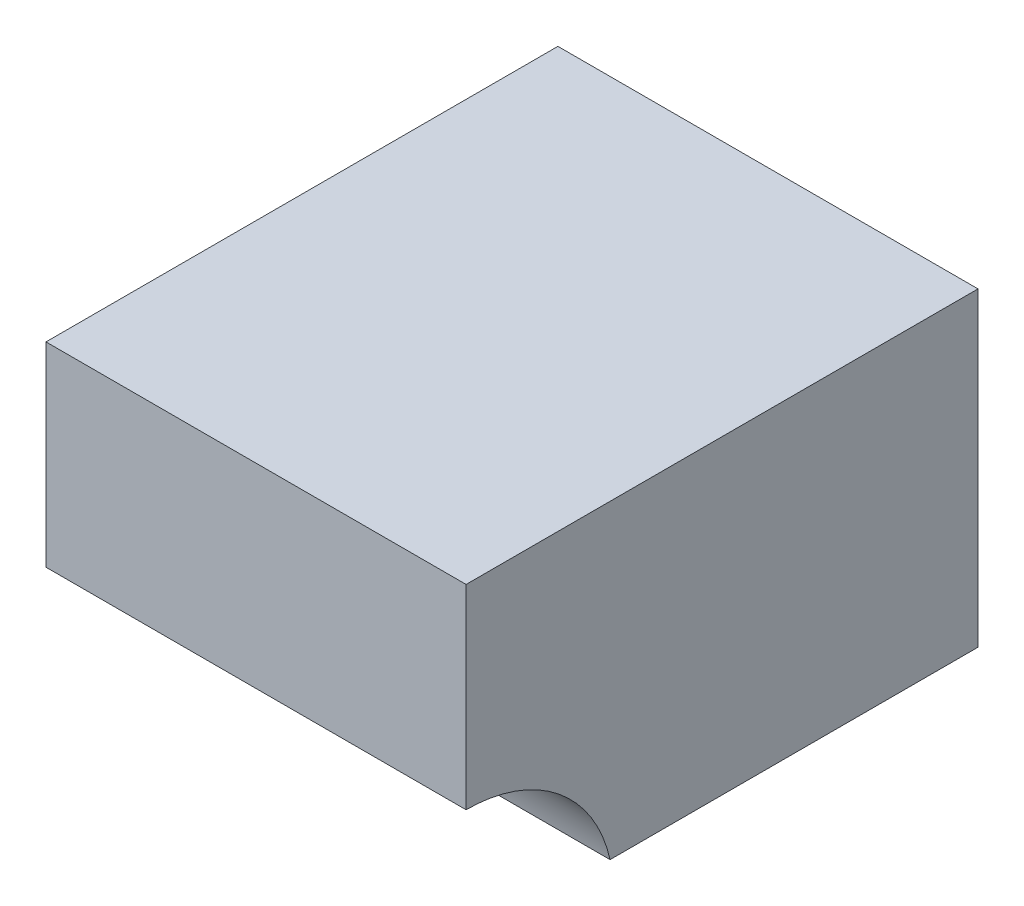
from build123d import *

# Parameters (mm, degrees)
BOSS_EXTRUDE1_DEPTH = 33.3502


with BuildPart() as part:
    # Sketch1 → Boss-Extrude1 (new body)
    with BuildSketch(Plane(origin=(0, 0, 0), x_dir=(0, 0, -1), z_dir=(1, 0, 0))):
        with BuildLine():
            Line((-40.64, 24.638), (0, 24.638))
            Line((0, 24.638), (0, 0))
            Line((0, 0), (-29.21, 0))
            ThreePointArc((-29.21, 0), (-33.321228997, 6.576713754), (-40.64, 9.144))
            Line((-40.64, 9.144), (-40.64, 24.638))
        make_face()
    extrude(amount=BOSS_EXTRUDE1_DEPTH)


solid = part.part
